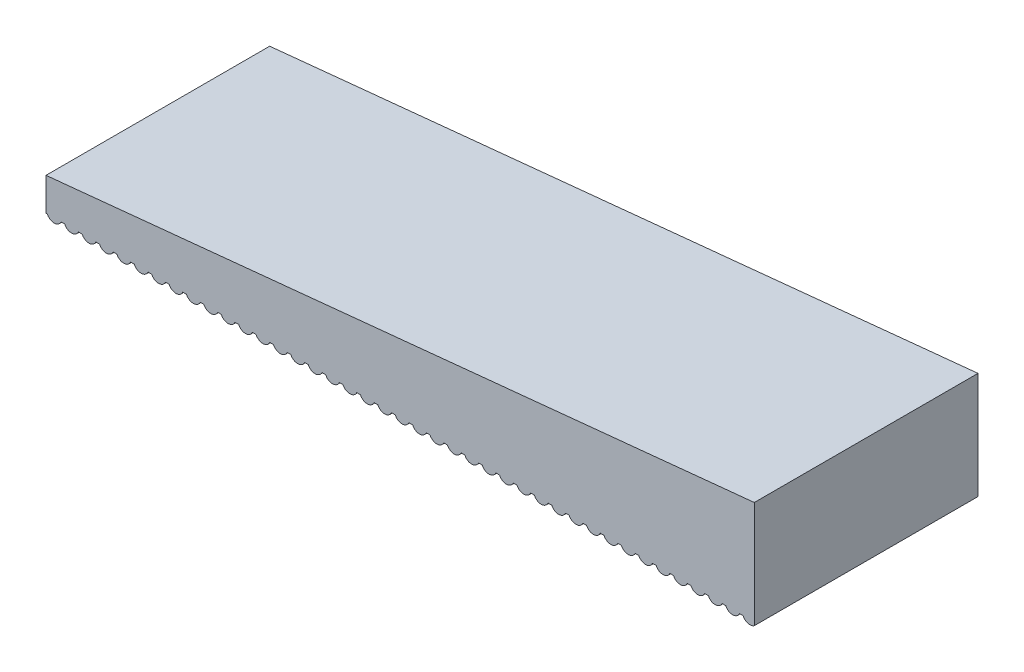
from build123d import *

# Parameters (mm, degrees)
BOSS_EXTRUDE1_DEPTH     = 1.5
SKETCH2_OUTSIDE_W       = 14.11
SKETCH2_OUTSIDE_H       = 5.61
CUT_EXTRUDE1_DEPTH      = 1
CUT_EXTRUDE1_DEPTH_BACK = 4
CUT_EXTRUDE2_DEPTH      = 0.5


with BuildPart() as part:
    # Sketch1 → Boss-Extrude1 (new body, symmetric)
    with BuildSketch(Plane.XY):
        Polygon((0, 0), (10, 1), (10, -0.5), (0, -0.5), align=None)
    extrude(amount=BOSS_EXTRUDE1_DEPTH, both=True)

    # Sketch2 outside → Cut-Extrude1 (cut, two sides)
    with BuildSketch(Plane.XY.offset(1.5)) as cut_extrude1_sk:
        with Locations((5, 0.25)):
            Rectangle(SKETCH2_OUTSIDE_W, SKETCH2_OUTSIDE_H)
        with BuildLine():
            Line((9.816696972, -0.44), (9.766696972, -0.44))
            ThreePointArc((9.766696972, -0.44), (9.675045458, -0.5), (9.583393944, -0.44))
            Line((9.583393944, -0.44), (9.533393944, -0.44))
            ThreePointArc((9.533393944, -0.44), (9.441742431, -0.5), (9.350090917, -0.44))
            Line((9.350090917, -0.44), (9.300090917, -0.44))
            ThreePointArc((9.300090917, -0.44), (9.208439403, -0.5), (9.116787889, -0.44))
            Line((9.116787889, -0.44), (9.066787889, -0.44))
            ThreePointArc((9.066787889, -0.44), (8.975136375, -0.5), (8.883484861, -0.44))
            Line((8.883484861, -0.44), (8.833484861, -0.44))
            ThreePointArc((8.833484861, -0.44), (8.741833347, -0.5), (8.650181833, -0.44))
            Line((8.650181833, -0.44), (8.600181833, -0.44))
            ThreePointArc((8.600181833, -0.44), (8.508530319, -0.5), (8.416878805, -0.44))
            Line((8.416878805, -0.44), (8.366878805, -0.44))
            ThreePointArc((8.366878805, -0.44), (8.275227292, -0.5), (8.183575778, -0.44))
            Line((8.183575778, -0.44), (8.133575778, -0.44))
            ThreePointArc((8.133575778, -0.44), (8.041924264, -0.5), (7.95027275, -0.44))
            Line((7.95027275, -0.44), (7.90027275, -0.44))
            ThreePointArc((7.90027275, -0.44), (7.808621236, -0.5), (7.716969722, -0.44))
            Line((7.716969722, -0.44), (7.666969722, -0.44))
            ThreePointArc((7.666969722, -0.44), (7.575318208, -0.5), (7.483666694, -0.44))
            Line((7.483666694, -0.44), (7.433666694, -0.44))
            ThreePointArc((7.433666694, -0.44), (7.34201518, -0.5), (7.250363666, -0.44))
            Line((7.250363666, -0.44), (7.200363666, -0.44))
            ThreePointArc((7.200363666, -0.44), (7.108712153, -0.5), (7.017060639, -0.44))
            Line((7.017060639, -0.44), (6.967060639, -0.44))
            ThreePointArc((6.967060639, -0.44), (6.875409125, -0.5), (6.783757611, -0.44))
            Line((6.783757611, -0.44), (6.733757611, -0.44))
            ThreePointArc((6.733757611, -0.44), (6.642106097, -0.5), (6.550454583, -0.44))
            Line((6.550454583, -0.44), (6.500454583, -0.44))
            ThreePointArc((6.500454583, -0.44), (6.408803069, -0.5), (6.317151555, -0.44))
            Line((6.317151555, -0.44), (6.267151555, -0.44))
            ThreePointArc((6.267151555, -0.44), (6.175500041, -0.5), (6.083848527, -0.44))
            Line((6.083848527, -0.44), (6.033848527, -0.44))
            ThreePointArc((6.033848527, -0.44), (5.942197014, -0.5), (5.8505455, -0.44))
            Line((5.8505455, -0.44), (5.8005455, -0.44))
            ThreePointArc((5.8005455, -0.44), (5.708893986, -0.5), (5.617242472, -0.44))
            Line((5.617242472, -0.44), (5.567242472, -0.44))
            ThreePointArc((5.567242472, -0.44), (5.475590958, -0.5), (5.383939444, -0.44))
            Line((5.383939444, -0.44), (5.333939444, -0.44))
            ThreePointArc((5.333939444, -0.44), (5.24228793, -0.5), (5.150636416, -0.44))
            Line((5.150636416, -0.44), (5.100636416, -0.44))
            ThreePointArc((5.100636416, -0.44), (5.008984902, -0.5), (4.917333388, -0.44))
            Line((4.917333388, -0.44), (4.867333388, -0.44))
            ThreePointArc((4.867333388, -0.44), (4.775681875, -0.5), (4.684030361, -0.44))
            Line((4.684030361, -0.44), (4.634030361, -0.44))
            ThreePointArc((4.634030361, -0.44), (4.542378847, -0.5), (4.450727333, -0.44))
            Line((4.450727333, -0.44), (4.400727333, -0.44))
            ThreePointArc((4.400727333, -0.44), (4.309075819, -0.5), (4.217424305, -0.44))
            Line((4.217424305, -0.44), (4.167424305, -0.44))
            ThreePointArc((4.167424305, -0.44), (4.075772791, -0.5), (3.984121277, -0.44))
            Line((3.984121277, -0.44), (3.934121277, -0.44))
            ThreePointArc((3.934121277, -0.44), (3.842469763, -0.5), (3.750818249, -0.44))
            Line((3.750818249, -0.44), (3.700818249, -0.44))
            ThreePointArc((3.700818249, -0.44), (3.609166736, -0.5), (3.517515222, -0.44))
            Line((3.517515222, -0.44), (3.467515222, -0.44))
            ThreePointArc((3.467515222, -0.44), (3.375863708, -0.5), (3.284212194, -0.44))
            Line((3.284212194, -0.44), (3.234212194, -0.44))
            ThreePointArc((3.234212194, -0.44), (3.14256068, -0.5), (3.050909166, -0.44))
            Line((3.050909166, -0.44), (3.000909166, -0.44))
            ThreePointArc((3.000909166, -0.44), (2.909257652, -0.5), (2.817606138, -0.44))
            Line((2.817606138, -0.44), (2.767606138, -0.44))
            ThreePointArc((2.767606138, -0.44), (2.675954624, -0.5), (2.58430311, -0.44))
            Line((2.58430311, -0.44), (2.53430311, -0.44))
            ThreePointArc((2.53430311, -0.44), (2.442651597, -0.5), (2.351000083, -0.44))
            Line((2.351000083, -0.44), (2.301000083, -0.44))
            ThreePointArc((2.301000083, -0.44), (2.209348569, -0.5), (2.117697055, -0.44))
            Line((2.117697055, -0.44), (2.067697055, -0.44))
            ThreePointArc((2.067697055, -0.44), (1.976045541, -0.5), (1.884394027, -0.44))
            Line((1.884394027, -0.44), (1.834394027, -0.44))
            ThreePointArc((1.834394027, -0.44), (1.742742513, -0.5), (1.651090999, -0.44))
            Line((1.651090999, -0.44), (1.601090999, -0.44))
            ThreePointArc((1.601090999, -0.44), (1.509439485, -0.5), (1.417787971, -0.44))
            Line((1.417787971, -0.44), (1.367787971, -0.44))
            ThreePointArc((1.367787971, -0.44), (1.276136458, -0.5), (1.184484944, -0.44))
            Line((1.184484944, -0.44), (1.134484944, -0.44))
            ThreePointArc((1.134484944, -0.44), (1.04283343, -0.5), (0.951181916, -0.44))
            Line((0.951181916, -0.44), (0.901181916, -0.44))
            ThreePointArc((0.901181916, -0.44), (0.809530402, -0.5), (0.717878888, -0.44))
            Line((0.717878888, -0.44), (0.667878888, -0.44))
            ThreePointArc((0.667878888, -0.44), (0.576227374, -0.5), (0.48457586, -0.44))
            Line((0.48457586, -0.44), (0.43457586, -0.44))
            ThreePointArc((0.43457586, -0.44), (0.342924346, -0.5), (0.251272832, -0.44))
            Line((0.251272832, -0.44), (0.201272832, -0.44))
            ThreePointArc((0.201272832, -0.44), (0.109621319, -0.5), (0.017969805, -0.44))
            Line((0.017969805, -0.44), (0, -0.44))
            Line((0, -0.44), (0, 0))
            Line((0, 0), (10, 1))
            Line((10, 1), (10, -0.44))
            ThreePointArc((10, -0.44), (9.908348486, -0.5), (9.816696972, -0.44))
        make_face(mode=Mode.SUBTRACT)
    extrude(amount=CUT_EXTRUDE1_DEPTH, mode=Mode.SUBTRACT)
    extrude(cut_extrude1_sk.sketch, amount=-CUT_EXTRUDE1_DEPTH_BACK, mode=Mode.SUBTRACT)

    # Sketch4 → Cut-Extrude2 (cut)
    with BuildSketch(Plane(origin=(10, 0, 0), x_dir=(0, 0, -1), z_dir=(1, 0, 0))):
        Polygon((-1.5, -0.5), (1.5, -0.5), (1.5, -0.44), (1.5, 1), (-1.5, 1), (-1.500006, -0.44), align=None)
    extrude(amount=-CUT_EXTRUDE2_DEPTH, mode=Mode.SUBTRACT)


solid = part.part
